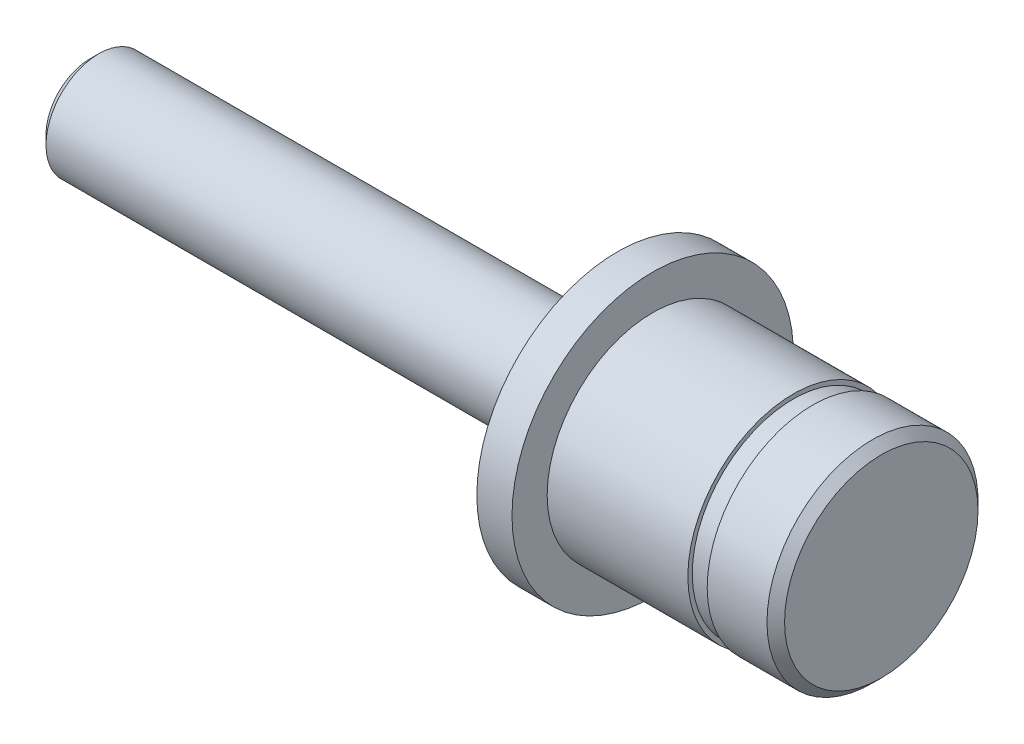
from build123d import *

# Parameters (mm, degrees)
CHAMFER1_SIZE = 0.5


with BuildPart() as part:
    # Sketch1 → Revolve1 (revolve)
    with BuildSketch(Plane.XY):
        Polygon((45, 0), (45, 6), (41.1, 6), (41.1, 5.75), (40, 5.75), (40, 6), (32, 6), (32, 8), (30, 8), (30, 3), (0, 3), (0, 0), align=None)
    revolve(axis=Axis((-588.066908311, 0, 0), (1, 0, 0)))

    # Chamfer1
    chamfer1_edges = [part.edges().sort_by_distance(p)[0] for p in [
        (45, -6, 0),
        (0, -3, 0),
    ]]
    chamfer(chamfer1_edges, length=CHAMFER1_SIZE)


solid = part.part
